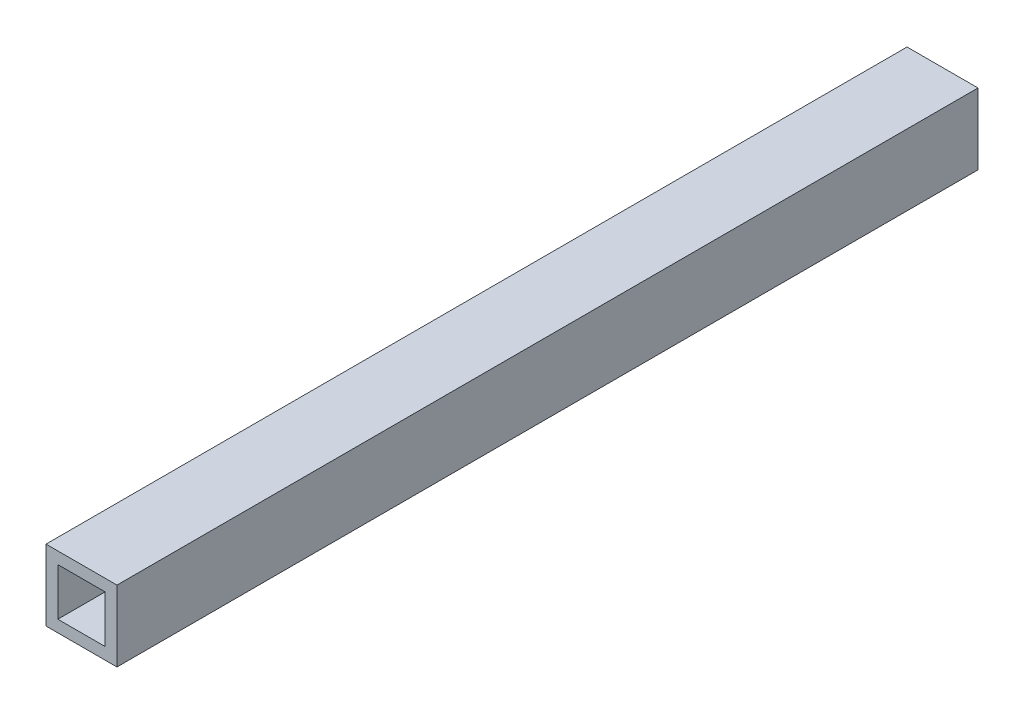
from build123d import *

# Parameters (mm, degrees)
SKETCH1_W           = 19.05
SKETCH1_H           = 19.05
SKETCH1_W_2         = 12.7
SKETCH1_H_2         = 12.7
BOSS_EXTRUDE1_DEPTH = 231.14


with BuildPart() as part:
    # Sketch1 → Boss-Extrude1 (new body)
    with BuildSketch(Plane.XY):
        Rectangle(SKETCH1_W, SKETCH1_H)
        Rectangle(SKETCH1_W_2, SKETCH1_H_2, mode=Mode.SUBTRACT)
    extrude(amount=BOSS_EXTRUDE1_DEPTH)


solid = part.part
